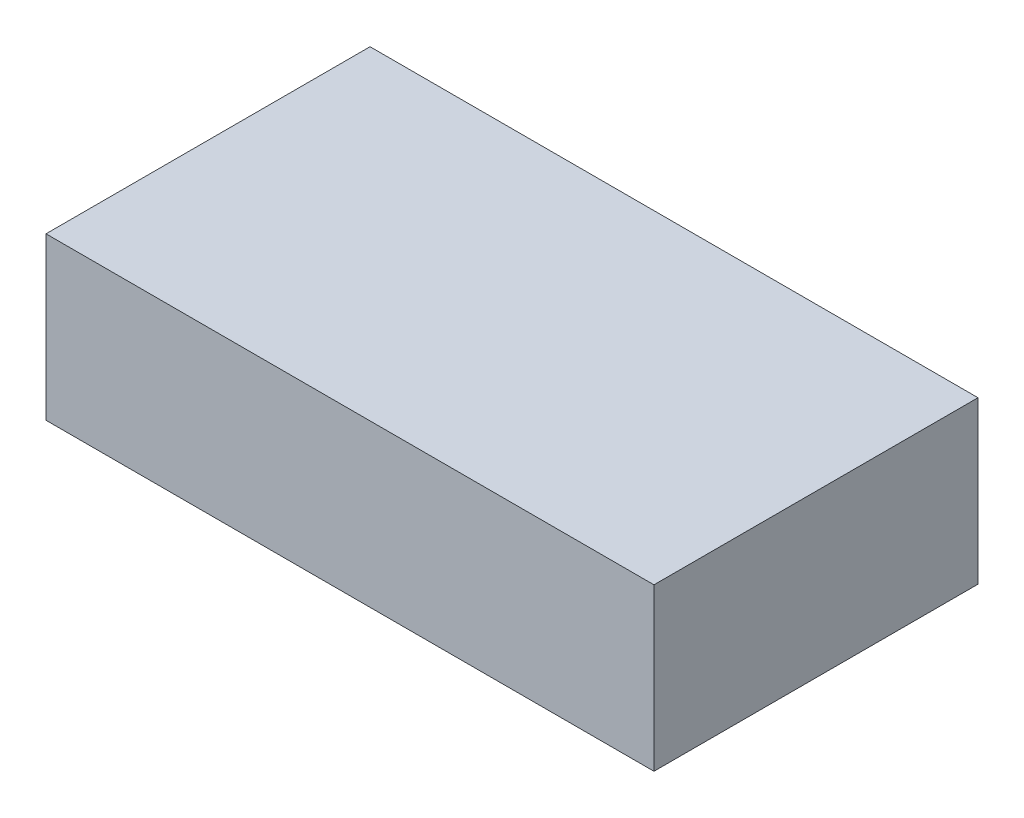
from build123d import *

# Parameters (mm, degrees)
CROQUIS1_W              = 150.114
CROQUIS1_H              = 80.01
SALIENTE_EXTRUIR1_DEPTH = 39.878


with BuildPart() as part:
    # Croquis1 → Saliente-Extruir1 (new body)
    with BuildSketch(Plane(origin=(0, 0, 0), x_dir=(1, 0, 0), z_dir=(0, 1, 0))):
        Rectangle(CROQUIS1_W, CROQUIS1_H)
    extrude(amount=SALIENTE_EXTRUIR1_DEPTH)


solid = part.part
